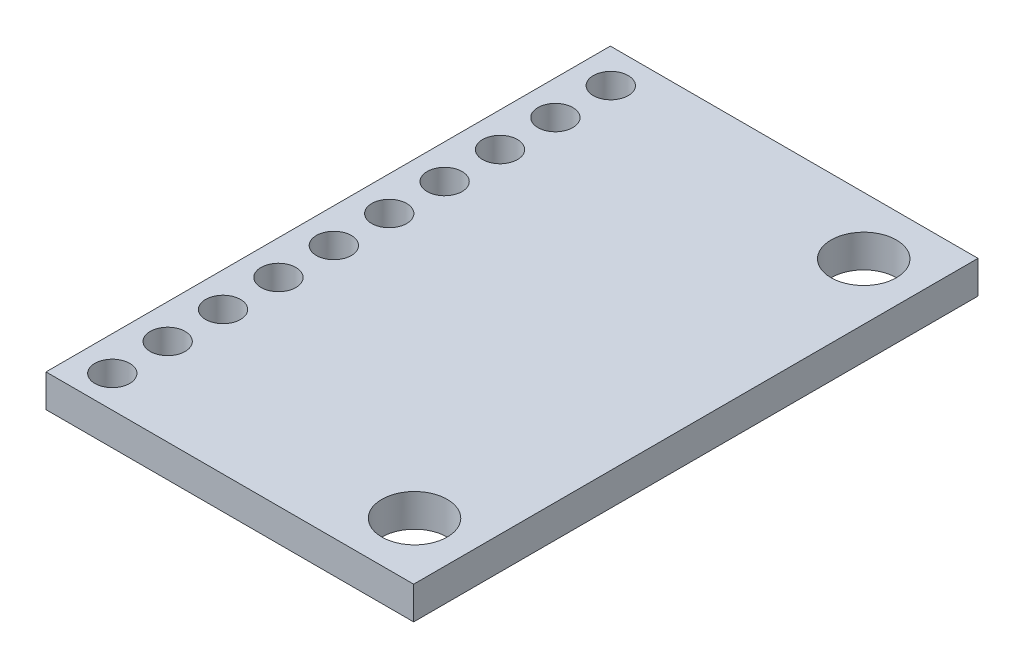
from build123d import *

# Parameters (mm, degrees)
SKETCH1_W           = 16.86
SKETCH1_H           = 25.88
BOSS_EXTRUDE1_DEPTH = 1.5
CUT_EXTRUDE1_REACH  = 3.5
SKETCH2_R           = 1.5
CUT_EXTRUDE2_REACH  = 3.5
SKETCH3_R           = 0.8


with BuildPart() as part:
    # Sketch1 → Boss-Extrude1 (new body)
    with BuildSketch(Plane(origin=(0, 0, 0), x_dir=(1, 0, 0), z_dir=(0, 1, 0))):
        with Locations((8.43, 12.94)):
            Rectangle(SKETCH1_W, SKETCH1_H)
    extrude(amount=BOSS_EXTRUDE1_DEPTH)

    # Sketch2 → Cut-Extrude1 (cut, up to next)
    with BuildSketch(Plane(origin=(0, 1.5, 0), x_dir=(1, 0, 0), z_dir=(0, 1, 0)), mode=Mode.PRIVATE) as cut_extrude1_sk1:
        with Locations((14.26, 23.24)):
            Circle(SKETCH2_R)
    cut_extrude1_tool1 = extrude(cut_extrude1_sk1.sketch, amount=-CUT_EXTRUDE1_REACH, mode=Mode.PRIVATE) & part.part
    add(cut_extrude1_tool1.solids().sort_by_distance((14.26, 1.5, -23.24))[0], mode=Mode.SUBTRACT)
    # Sketch2 → Cut-Extrude1 (cut, up to next)
    with BuildSketch(Plane(origin=(0, 1.5, 0), x_dir=(1, 0, 0), z_dir=(0, 1, 0)), mode=Mode.PRIVATE) as cut_extrude1_sk2:
        with Locations((14.26, 2.64)):
            Circle(SKETCH2_R)
    cut_extrude1_tool2 = extrude(cut_extrude1_sk2.sketch, amount=-CUT_EXTRUDE1_REACH, mode=Mode.PRIVATE) & part.part
    add(cut_extrude1_tool2.solids().sort_by_distance((14.26, 1.5, -2.64))[0], mode=Mode.SUBTRACT)

    # Sketch3 → Cut-Extrude2 (cut, up to next)
    with BuildSketch(Plane(origin=(0, 1.5, 0), x_dir=(1, 0, 0), z_dir=(0, 1, 0)), mode=Mode.PRIVATE) as cut_extrude2_sk1:
        with Locations((1.58, 24.32)):
            Circle(SKETCH3_R)
    cut_extrude2_tool1 = extrude(cut_extrude2_sk1.sketch, amount=-CUT_EXTRUDE2_REACH, mode=Mode.PRIVATE) & part.part
    add(cut_extrude2_tool1.solids().sort_by_distance((1.58, 1.5, -24.32))[0], mode=Mode.SUBTRACT)
    # Sketch3 → Cut-Extrude2 (cut, up to next)
    with BuildSketch(Plane(origin=(0, 1.5, 0), x_dir=(1, 0, 0), z_dir=(0, 1, 0)), mode=Mode.PRIVATE) as cut_extrude2_sk2:
        with Locations((1.58, 21.78)):
            Circle(SKETCH3_R)
    cut_extrude2_tool2 = extrude(cut_extrude2_sk2.sketch, amount=-CUT_EXTRUDE2_REACH, mode=Mode.PRIVATE) & part.part
    add(cut_extrude2_tool2.solids().sort_by_distance((1.58, 1.5, -21.78))[0], mode=Mode.SUBTRACT)
    # Sketch3 → Cut-Extrude2 (cut, up to next)
    with BuildSketch(Plane(origin=(0, 1.5, 0), x_dir=(1, 0, 0), z_dir=(0, 1, 0)), mode=Mode.PRIVATE) as cut_extrude2_sk3:
        with Locations((1.58, 19.24)):
            Circle(SKETCH3_R)
    cut_extrude2_tool3 = extrude(cut_extrude2_sk3.sketch, amount=-CUT_EXTRUDE2_REACH, mode=Mode.PRIVATE) & part.part
    add(cut_extrude2_tool3.solids().sort_by_distance((1.58, 1.5, -19.24))[0], mode=Mode.SUBTRACT)
    # Sketch3 → Cut-Extrude2 (cut, up to next)
    with BuildSketch(Plane(origin=(0, 1.5, 0), x_dir=(1, 0, 0), z_dir=(0, 1, 0)), mode=Mode.PRIVATE) as cut_extrude2_sk4:
        with Locations((1.58, 16.7)):
            Circle(SKETCH3_R)
    cut_extrude2_tool4 = extrude(cut_extrude2_sk4.sketch, amount=-CUT_EXTRUDE2_REACH, mode=Mode.PRIVATE) & part.part
    add(cut_extrude2_tool4.solids().sort_by_distance((1.58, 1.5, -16.7))[0], mode=Mode.SUBTRACT)
    # Sketch3 → Cut-Extrude2 (cut, up to next)
    with BuildSketch(Plane(origin=(0, 1.5, 0), x_dir=(1, 0, 0), z_dir=(0, 1, 0)), mode=Mode.PRIVATE) as cut_extrude2_sk5:
        with Locations((1.58, 14.16)):
            Circle(SKETCH3_R)
    cut_extrude2_tool5 = extrude(cut_extrude2_sk5.sketch, amount=-CUT_EXTRUDE2_REACH, mode=Mode.PRIVATE) & part.part
    add(cut_extrude2_tool5.solids().sort_by_distance((1.58, 1.5, -14.16))[0], mode=Mode.SUBTRACT)
    # Sketch3 → Cut-Extrude2 (cut, up to next)
    with BuildSketch(Plane(origin=(0, 1.5, 0), x_dir=(1, 0, 0), z_dir=(0, 1, 0)), mode=Mode.PRIVATE) as cut_extrude2_sk6:
        with Locations((1.58, 11.62)):
            Circle(SKETCH3_R)
    cut_extrude2_tool6 = extrude(cut_extrude2_sk6.sketch, amount=-CUT_EXTRUDE2_REACH, mode=Mode.PRIVATE) & part.part
    add(cut_extrude2_tool6.solids().sort_by_distance((1.58, 1.5, -11.62))[0], mode=Mode.SUBTRACT)
    # Sketch3 → Cut-Extrude2 (cut, up to next)
    with BuildSketch(Plane(origin=(0, 1.5, 0), x_dir=(1, 0, 0), z_dir=(0, 1, 0)), mode=Mode.PRIVATE) as cut_extrude2_sk7:
        with Locations((1.58, 9.08)):
            Circle(SKETCH3_R)
    cut_extrude2_tool7 = extrude(cut_extrude2_sk7.sketch, amount=-CUT_EXTRUDE2_REACH, mode=Mode.PRIVATE) & part.part
    add(cut_extrude2_tool7.solids().sort_by_distance((1.58, 1.5, -9.08))[0], mode=Mode.SUBTRACT)
    # Sketch3 → Cut-Extrude2 (cut, up to next)
    with BuildSketch(Plane(origin=(0, 1.5, 0), x_dir=(1, 0, 0), z_dir=(0, 1, 0)), mode=Mode.PRIVATE) as cut_extrude2_sk8:
        with Locations((1.58, 6.54)):
            Circle(SKETCH3_R)
    cut_extrude2_tool8 = extrude(cut_extrude2_sk8.sketch, amount=-CUT_EXTRUDE2_REACH, mode=Mode.PRIVATE) & part.part
    add(cut_extrude2_tool8.solids().sort_by_distance((1.58, 1.5, -6.54))[0], mode=Mode.SUBTRACT)
    # Sketch3 → Cut-Extrude2 (cut, up to next)
    with BuildSketch(Plane(origin=(0, 1.5, 0), x_dir=(1, 0, 0), z_dir=(0, 1, 0)), mode=Mode.PRIVATE) as cut_extrude2_sk9:
        with Locations((1.58, 4)):
            Circle(SKETCH3_R)
    cut_extrude2_tool9 = extrude(cut_extrude2_sk9.sketch, amount=-CUT_EXTRUDE2_REACH, mode=Mode.PRIVATE) & part.part
    add(cut_extrude2_tool9.solids().sort_by_distance((1.58, 1.5, -4))[0], mode=Mode.SUBTRACT)
    # Sketch3 → Cut-Extrude2 (cut, up to next)
    with BuildSketch(Plane(origin=(0, 1.5, 0), x_dir=(1, 0, 0), z_dir=(0, 1, 0)), mode=Mode.PRIVATE) as cut_extrude2_sk10:
        with Locations((1.58, 1.46)):
            Circle(SKETCH3_R)
    cut_extrude2_tool10 = extrude(cut_extrude2_sk10.sketch, amount=-CUT_EXTRUDE2_REACH, mode=Mode.PRIVATE) & part.part
    add(cut_extrude2_tool10.solids().sort_by_distance((1.58, 1.5, -1.46))[0], mode=Mode.SUBTRACT)


solid = part.part
